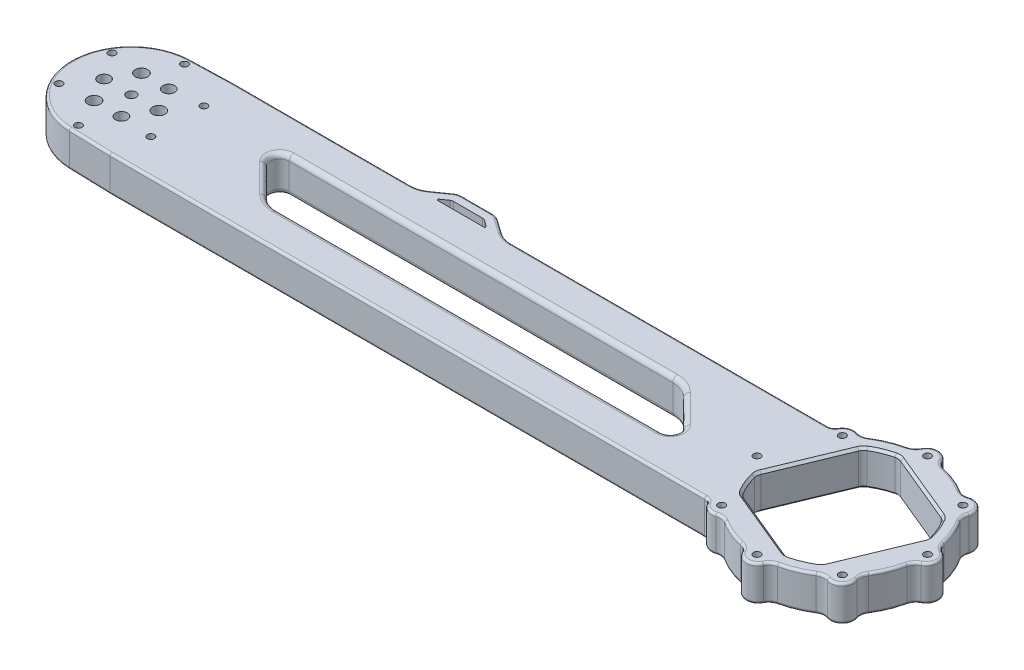
from build123d import *

# Parameters (mm, degrees)
SKETCH_1_R               = 2
SKETCH_1_R_2             = 1.5
EXTRUDE_1_DEPTH          = 15
CUT_EXTRUDE_1_DEPTH      = 1
CUT_EXTRUDE_1_DEPTH_BACK = 16
FILLET_1_R               = 5
FILLET_3_R               = 3
SKETCH_4_R               = 2.5
SKETCH_4_R_2             = 2.65
CUT_EXTRUDE_2_DEPTH      = 1.0000001
CUT_EXTRUDE_2_DEPTH_BACK = 16.0000001
EXTRUDE_2_DEPTH          = 15
CUT_EXTRUDE_3_DEPTH      = 16.0000001
FILLET_6_R               = 10
FILLET_4_R               = 1
FILLET_5_R               = 2
CHAMFER_1_SIZE           = 1


with BuildPart() as part:
    # 草图1 → 凸台-拉伸1 (new body)
    with BuildSketch(Plane(origin=(0, 0, 0), x_dir=(1, 0, 0), z_dir=(0, 1, 0))):
        with BuildLine():
            Line((16.881943016, 26), (255.487007442, 26))
            ThreePointArc((255.487007442, 26), (260.754446137, 26.518797429), (265.819460116, 28.055252622))
            Line((265.819460116, 28.055252622), (296.173165676, 40.628169134))
            ThreePointArc((296.173165676, 40.628169134), (300, 41.389373808), (303.826834324, 40.628169134))
            Line((303.826834324, 40.628169134), (326.022473401, 31.434434402))
            ThreePointArc((326.022473401, 31.434434402), (329.266706889, 29.266706889), (331.434434402, 26.022473401))
            Line((331.434434402, 26.022473401), (340.628169134, 3.826834324))
            ThreePointArc((340.628169134, 3.826834324), (341.389373808, 0), (340.628169134, -3.826834324))
            Line((340.628169134, -3.826834324), (331.434434402, -26.022473401))
            ThreePointArc((331.434434402, -26.022473401), (329.266706889, -29.266706889), (326.022473401, -31.434434402))
            Line((326.022473401, -31.434434402), (303.826834324, -40.628169134))
            ThreePointArc((303.826834324, -40.628169134), (300, -41.389373808), (296.173165676, -40.628169134))
            Line((296.173165676, -40.628169134), (265.819460116, -28.055252622))
            ThreePointArc((265.819460116, -28.055252622), (260.754446137, -26.518797429), (255.487007442, -26))
            Line((255.487007442, -26), (16.881943016, -26))
            Line((16.881943016, -26), (-0.738760201, -25.489296447))
            ThreePointArc((-0.738760201, -25.489296447), (-25.5, 0), (-0.738760201, 25.489296447))
            Line((-0.738760201, 25.489296447), (16.881943016, 26))
        make_face()
        Circle(SKETCH_1_R, mode=Mode.SUBTRACT)
        with Locations((0, 22.375)):
            Circle(SKETCH_1_R_2, mode=Mode.SUBTRACT)
        with Locations((19.37731841, 11.1875)):
            Circle(SKETCH_1_R_2, mode=Mode.SUBTRACT)
        with Locations((19.37731841, -11.1875)):
            Circle(SKETCH_1_R_2, mode=Mode.SUBTRACT)
        with Locations((0, -22.375)):
            Circle(SKETCH_1_R_2, mode=Mode.SUBTRACT)
        with Locations((-19.37731841, -11.1875)):
            Circle(SKETCH_1_R_2, mode=Mode.SUBTRACT)
        with Locations((-19.37731841, 11.1875)):
            Circle(SKETCH_1_R_2, mode=Mode.SUBTRACT)
        with Locations((300, 36)):
            Circle(SKETCH_1_R_2, mode=Mode.SUBTRACT)
        with Locations((325.455844123, 25.455844123)):
            Circle(SKETCH_1_R_2, mode=Mode.SUBTRACT)
        with Locations((336, 0)):
            Circle(SKETCH_1_R_2, mode=Mode.SUBTRACT)
        with Locations((325.455844123, -25.455844123)):
            Circle(SKETCH_1_R_2, mode=Mode.SUBTRACT)
        with Locations((300, -36)):
            Circle(SKETCH_1_R_2, mode=Mode.SUBTRACT)
        with Locations((274.544155877, -25.455844123)):
            Circle(SKETCH_1_R_2, mode=Mode.SUBTRACT)
        with Locations((264, 0)):
            Circle(SKETCH_1_R_2, mode=Mode.SUBTRACT)
        with Locations((274.544155877, 25.455844123)):
            Circle(SKETCH_1_R_2, mode=Mode.SUBTRACT)
        with BuildLine():
            Line((295.11620408, 29.407457173), (324.247577598, 17.340847172))
            ThreePointArc((324.247577598, 17.340847172), (325.328094971, 16.675406215), (326.145801434, 15.70500135))
            ThreePointArc((326.145801434, 15.70500135), (328.178325742, 11.671844687), (329.592986446, 7.38276054))
            ThreePointArc((329.592986446, 7.38276054), (329.700960523, 6.118374895), (329.407457173, 4.88379592))
            Line((329.407457173, 4.88379592), (317.340847172, -24.247577598))
            ThreePointArc((317.340847172, -24.247577598), (316.675406215, -25.328094971), (315.70500135, -26.145801434))
            ThreePointArc((315.70500135, -26.145801434), (311.671844687, -28.178325742), (307.38276054, -29.592986446))
            ThreePointArc((307.38276054, -29.592986446), (306.118374895, -29.700960523), (304.88379592, -29.407457173))
            Line((304.88379592, -29.407457173), (275.752422402, -17.340847172))
            ThreePointArc((275.752422402, -17.340847172), (274.671905029, -16.675406215), (273.854198566, -15.70500135))
            ThreePointArc((273.854198566, -15.70500135), (271.821674258, -11.671844687), (270.407013554, -7.38276054))
            ThreePointArc((270.407013554, -7.38276054), (270.299039477, -6.118374895), (270.592542827, -4.88379592))
            Line((270.592542827, -4.88379592), (282.659152828, 24.247577598))
            ThreePointArc((282.659152828, 24.247577598), (283.324593785, 25.328094971), (284.29499865, 26.145801434))
            ThreePointArc((284.29499865, 26.145801434), (288.328155313, 28.178325742), (292.61723946, 29.592986446))
            ThreePointArc((292.61723946, 29.592986446), (293.881625105, 29.700960523), (295.11620408, 29.407457173))
        make_face(mode=Mode.SUBTRACT)
    extrude(amount=EXTRUDE_1_DEPTH)

    # 草图2 → 切除-拉伸1 (cut, two sides)
    with BuildSketch(Plane(origin=(0, 15, 0), x_dir=(1, 0, 0), z_dir=(0, 1, 0))) as cut_extrude_1_sk:
        with BuildLine():
            Line((255.487007442, 26), (269.97895759, 26))
            ThreePointArc((269.97895759, 26), (273.336357863, 29.852257236), (278.324559852, 28.7432652))
            ThreePointArc((278.324559852, 28.7432652), (286.223396435, 33.25966317), (295.002292978, 35.651408451))
            ThreePointArc((295.002292978, 35.651408451), (300, 40.5), (304.997707022, 35.651408451))
            ThreePointArc((304.997707022, 35.651408451), (313.776603565, 33.25966317), (321.675440148, 28.7432652))
            ThreePointArc((321.675440148, 28.7432652), (328.637824638, 28.637824638), (328.7432652, 21.675440148))
            ThreePointArc((328.7432652, 21.675440148), (333.25966317, 13.776603565), (335.651408451, 4.997707022))
            ThreePointArc((335.651408451, 4.997707022), (340.5, 0), (335.651408451, -4.997707022))
            ThreePointArc((335.651408451, -4.997707022), (333.25966317, -13.776603565), (328.7432652, -21.675440148))
            ThreePointArc((328.7432652, -21.675440148), (328.637824638, -28.637824638), (321.675440148, -28.7432652))
            ThreePointArc((321.675440148, -28.7432652), (313.776603565, -33.25966317), (304.997707022, -35.651408451))
            ThreePointArc((304.997707022, -35.651408451), (300, -40.5), (295.002292978, -35.651408451))
            ThreePointArc((295.002292978, -35.651408451), (286.223396435, -33.25966317), (278.324559852, -28.7432652))
            ThreePointArc((278.324559852, -28.7432652), (273.336357863, -29.852257236), (269.97895759, -26))
            Line((269.97895759, -26), (255.487007442, -26))
            Line((255.487007442, -26), (255.487007442, -49.841054101))
            Line((255.487007442, -49.841054101), (351.599740465, -49.841054101))
            Line((351.599740465, -49.841054101), (351.599740465, 57.076421941))
            Line((351.599740465, 57.076421941), (255.487007442, 57.076421941))
            Line((255.487007442, 57.076421941), (255.487007442, 26))
        make_face()
        with BuildLine():
            Line((72.5, 11), (217.5, 11))
            ThreePointArc((217.5, 11), (228.5, 0), (217.5, -11))
            Line((217.5, -11), (72.5, -11))
            ThreePointArc((72.5, -11), (61.5, 0), (72.5, 11))
        make_face()
    extrude(amount=CUT_EXTRUDE_1_DEPTH, mode=Mode.SUBTRACT)
    extrude(cut_extrude_1_sk.sketch, amount=-CUT_EXTRUDE_1_DEPTH_BACK, mode=Mode.SUBTRACT)

    # 圆角1
    fillet_1_edges = [part.edges().sort_by_distance(p)[0] for p in [
        (295.002292978, 7.5, -35.651408451),
        (278.324559852, 7.5, -28.7432652),
        (278.324559852, 7.5, 28.7432652),
        (295.002292978, 7.5, 35.651408451),
        (304.997707022, 7.5, 35.651408451),
        (321.675440148, 7.5, 28.7432652),
        (328.7432652, 7.5, 21.675440148),
        (335.651408451, 7.5, 4.997707022),
        (335.651408451, 7.5, -4.997707022),
        (328.7432652, 7.5, -21.675440148),
        (321.675440148, 7.5, -28.7432652),
        (304.997707022, 7.5, -35.651408451),
    ]]
    fillet(fillet_1_edges, radius=FILLET_1_R)

    # 圆角3
    fillet_3_edges = [part.edges().sort_by_distance(p)[0] for p in [
        (269.97895759, 7.5, -26),
        (269.97895759, 7.5, 26),
    ]]
    fillet(fillet_3_edges, radius=FILLET_3_R)

    # 草图4 → 切除-拉伸2 (cut, two sides)
    with BuildSketch(Plane(origin=(0, 15, 0), x_dir=(1, 0, 0), z_dir=(0, 1, 0))) as cut_extrude_2_sk:
        with Locations((5.773502692, -10)):
            Circle(SKETCH_4_R)
        with Locations((-5.773502692, -10)):
            Circle(SKETCH_4_R_2)
        with Locations((-11.547005384, 0)):
            Circle(SKETCH_4_R)
        with Locations((11.547005384, 0)):
            Circle(SKETCH_4_R_2)
        with Locations((5.773502692, 10)):
            Circle(SKETCH_4_R)
        with Locations((-5.773502692, 10)):
            Circle(SKETCH_4_R_2)
    extrude(amount=CUT_EXTRUDE_2_DEPTH, mode=Mode.SUBTRACT)
    extrude(cut_extrude_2_sk.sketch, amount=-CUT_EXTRUDE_2_DEPTH_BACK, mode=Mode.SUBTRACT)

    # 草图5 → 凸台-拉伸2 (add)
    with BuildSketch(Plane(origin=(0, 15, 0), x_dir=(1, 0, 0), z_dir=(0, 1, 0))):
        with BuildLine():
            ThreePointArc((119.449381795, 33), (120.952910792, 32.768584754), (122.317263976, 32.095760221))
            Line((122.317263976, 32.095760221), (131.022911786, 26))
            Line((131.022911786, 26), (131.022911786, 20.524991125))
            Line((131.022911786, 20.524991125), (94.995742057, 20.524991125))
            Line((94.995742057, 20.524991125), (94.995742057, 26))
            Line((94.995742057, 26), (103.701389867, 32.095760221))
            ThreePointArc((103.701389867, 32.095760221), (105.065743051, 32.768584754), (106.569272049, 33))
            Line((106.569272049, 33), (119.449381795, 33))
        make_face()
        with BuildLine():
            ThreePointArc((122.780486683, 26), (123.161973463, 26.27971768), (123.009917257, 26.727660818))
            Line((123.009917257, 26.727660818), (120.281235878, 28.638304089))
            ThreePointArc((120.281235878, 28.638304089), (119.735494605, 28.907433901), (119.134083006, 29))
            Line((119.134083006, 29), (106.884570838, 29))
            ThreePointArc((106.884570838, 29), (106.283159239, 28.907433901), (105.737417965, 28.638304089))
            Line((105.737417965, 28.638304089), (103.008736586, 26.727660818))
            ThreePointArc((103.008736586, 26.727660818), (102.85668038, 26.27971768), (103.238167161, 26))
            Line((103.238167161, 26), (122.780486683, 26))
        make_face(mode=Mode.SUBTRACT)
    extrude(amount=-EXTRUDE_2_DEPTH)

    # 草图6 → 切除-拉伸3 (cut, through all)
    with BuildSketch(Plane(origin=(0, 15, 0), x_dir=(1, 0, 0), z_dir=(0, 1, 0))):
        with BuildLine():
            Line((64.721825407, -7.778174593), (52.772077939, 4.171572875))
            ThreePointArc((52.772077939, 4.171572875), (51.904986933, 8.530733729), (55.600505063, 11))
            Line((55.600505063, 11), (72.5, 11))
            ThreePointArc((72.5, 11), (62.337325142, 4.209517756), (64.721825407, -7.778174593))
        make_face()
        with BuildLine():
            Line((225.278174593, 7.778174593), (237.227922061, -4.171572875))
            ThreePointArc((237.227922061, -4.171572875), (238.095013067, -8.530733729), (234.399494937, -11))
            Line((234.399494937, -11), (217.5, -11))
            ThreePointArc((217.5, -11), (227.662674858, -4.209517756), (225.278174593, 7.778174593))
        make_face()
    extrude(amount=-CUT_EXTRUDE_3_DEPTH, mode=Mode.SUBTRACT)

    # 圆角6
    fillet_6_edges = [part.edges().sort_by_distance(p)[0] for p in [
        (131.022911786, 7.5, -26),
        (94.995742057, 7.5, -26),
    ]]
    fillet(fillet_6_edges, radius=FILLET_6_R)

    # 圆角4
    fillet_4_edges = [part.edges().sort_by_distance(p)[0] for p in [
        (8.071591407, 15, 25.744648224),
        (142.396694937, 15, 26),
        (142.396694937, 0, 26),
        (8.071591407, 0, 25.744648224),
        (-25.5, 0, 0),
        (8.071591407, 0, -25.744648224),
        (273.077425571, 15, 29.75917459),
        (273.077425571, 0, 29.75917459),
        (286.223396435, 15, 33.25966317),
        (286.223396435, 0, 33.25966317),
        (300, 15, 40.5),
        (300, 0, 40.5),
        (313.776603565, 15, 33.25966317),
        (313.776603565, 0, 33.25966317),
        (328.637824638, 15, 28.637824638),
        (328.637824638, 0, 28.637824638),
        (333.25966317, 15, 13.776603565),
        (333.25966317, 0, 13.776603565),
        (340.5, 15, 0),
        (340.5, 0, 0),
        (333.25966317, 15, -13.776603565),
        (333.25966317, 0, -13.776603565),
        (328.637824638, 15, -28.637824638),
        (328.637824638, 0, -28.637824638),
        (313.776603565, 15, -33.25966317),
        (313.776603565, 0, -33.25966317),
        (300, 15, -40.5),
        (300, 0, -40.5),
        (286.223396435, 15, -33.25966317),
        (286.223396435, 0, -33.25966317),
        (278.633512437, 15, 29.643918427),
        (278.633512437, 0, 29.643918427),
        (294.146972505, 15, 36.069803987),
        (294.146972505, 0, 36.069803987),
        (305.853027495, 15, 36.069803987),
        (305.853027495, 0, 36.069803987),
        (321.366487563, 15, 29.643918427),
        (321.366487563, 0, 29.643918427),
        (329.643918427, 15, 21.366487563),
        (329.643918427, 0, 21.366487563),
        (336.069803987, 15, 5.853027495),
        (336.069803987, 0, 5.853027495),
        (336.069803987, 15, -5.853027495),
        (336.069803987, 0, -5.853027495),
        (329.643918427, 15, -21.366487563),
        (329.643918427, 0, -21.366487563),
        (321.366487563, 15, -29.643918427),
        (321.366487563, 0, -29.643918427),
        (305.853027495, 15, -36.069803987),
        (305.853027495, 0, -36.069803987),
        (294.146972505, 15, -36.069803987),
        (294.146972505, 0, -36.069803987),
        (278.633512437, 15, -29.643918427),
        (278.633512437, 0, -29.643918427),
        (273.077425571, 15, -29.75917459),
        (273.077425571, 0, -29.75917459),
        (201.043673266, 0, -26),
        (201.043673266, 15, -26),
        (269.430505295, 15, 26.413020784),
        (269.430505295, 0, 26.413020784),
        (269.430505295, 15, -26.413020784),
        (269.430505295, 0, -26.413020784),
        (113.009326922, 15, -33),
        (105.065743051, 15, -32.768584754),
        (100.639954199, 15, -29.952119889),
        (125.378699644, 0, -29.952119889),
        (105.065743051, 0, -32.768584754),
        (113.009326922, 0, -33),
        (120.952910792, 0, -32.768584754),
        (120.952910792, 15, -32.768584754),
        (125.378699644, 15, -29.952119889),
        (100.639954199, 0, -29.952119889),
        (54.362348592, 15, -26),
        (54.362348592, 0, -26),
        (131.16884168, 15, -26.462830493),
        (131.16884168, 0, -26.462830493),
        (94.849812163, 15, -26.462830493),
        (94.849812163, 0, -26.462830493),
        (8.071591407, 15, -25.744648224),
        (-25.5, 15, 0),
    ]]
    fillet(fillet_4_edges, radius=FILLET_4_R)

    # 圆角5
    fillet_5_edges = [part.edges().sort_by_distance(p)[0] for p in [
        (136.550252532, 0, -11),
        (153.449747468, 0, 11),
        (153.449747468, 15, 11),
        (136.550252532, 15, -11),
        (221.709517756, 15, -10.162674858),
        (221.709517756, 0, -10.162674858),
        (68.290482244, 15, 10.162674858),
        (68.290482244, 0, 10.162674858),
        (58.746951673, 0, 1.803300859),
        (51.904986933, 0, -8.530733729),
        (51.904986933, 15, -8.530733729),
        (58.746951673, 15, 1.803300859),
        (231.253048327, 0, -1.803300859),
        (238.095013067, 0, 8.530733729),
        (238.095013067, 15, 8.530733729),
        (231.253048327, 15, -1.803300859),
    ]]
    fillet(fillet_5_edges, radius=FILLET_5_R)

    # 倒角1
    chamfer_1_edges = [part.edges().sort_by_distance(p)[0] for p in [
        (270.299039477, 0, 6.118374895),
        (271.821674258, 0, 11.671844687),
        (274.671905029, 0, 16.675406215),
        (290.318109161, 0, 23.374152173),
        (306.118374895, 0, 29.700960523),
        (311.671844687, 0, 28.178325742),
        (316.675406215, 0, 25.328094971),
        (323.374152173, 0, 9.681890839),
        (329.700960523, 0, -6.118374895),
        (328.178325742, 0, -11.671844687),
        (325.328094971, 0, -16.675406215),
        (309.681890839, 0, -23.374152173),
        (293.881625105, 0, -29.700960523),
        (288.328155313, 0, -28.178325742),
        (283.324593785, 0, -25.328094971),
        (276.625847827, 0, -9.681890839),
        (270.299039477, 15, 6.118374895),
        (271.821674258, 15, 11.671844687),
        (274.671905029, 15, 16.675406215),
        (290.318109161, 15, 23.374152173),
        (306.118374895, 15, 29.700960523),
        (311.671844687, 15, 28.178325742),
        (316.675406215, 15, 25.328094971),
        (323.374152173, 15, 9.681890839),
        (329.700960523, 15, -6.118374895),
        (328.178325742, 15, -11.671844687),
        (325.328094971, 15, -16.675406215),
        (309.681890839, 15, -23.374152173),
        (293.881625105, 15, -29.700960523),
        (288.328155313, 15, -28.178325742),
        (283.324593785, 15, -25.328094971),
        (276.625847827, 15, -9.681890839),
    ]]
    chamfer(chamfer_1_edges, length=CHAMFER_1_SIZE)


solid = part.part
